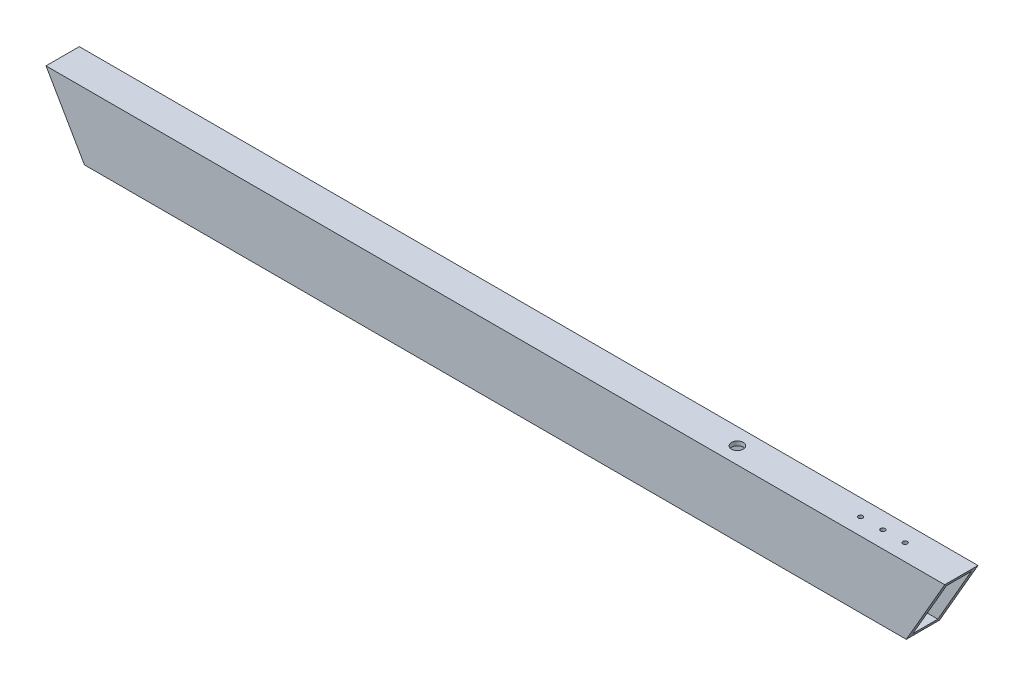
from build123d import *

# Parameters (mm, degrees)
SKETCH1_W                = 25.4
SKETCH1_H                = 50.8
SKETCH1_W_2              = 19.05
SKETCH1_H_2              = 44.45
BOSS_EXTRUDE1_DEPTH      = 342.9
CUT_EXTRUDE1_DEPTH       = 1
CUT_EXTRUDE1_DEPTH_BACK  = 26.4
CUT_EXTRUDE2_REACH       = 27.4
SKETCH3_R                = 11.1125
M3_CLEARANCE_HOLE1_D     = 3.4
M3_CLEARANCE_HOLE1_DEPTH = 3.175
SKETCH9_R                = 4.5
CUT_EXTRUDE3_DEPTH       = 12.7


with BuildPart() as part:
    # Sketch1 → Boss-Extrude1 (new body, symmetric)
    with BuildSketch(Plane(origin=(0, 0, 0), x_dir=(0, 0, -1), z_dir=(1, 0, 0))):
        Rectangle(SKETCH1_W, SKETCH1_H)
        Rectangle(SKETCH1_W_2, SKETCH1_H_2, mode=Mode.SUBTRACT)
    extrude(amount=BOSS_EXTRUDE1_DEPTH, both=True)

    # Sketch2 → Cut-Extrude1 (cut, two sides)
    with BuildSketch(Plane(origin=(0, 0, -12.7), x_dir=(-1, 0, 0), z_dir=(0, 0, -1))) as cut_extrude1_sk:
        Polygon((342.9, -25.4), (342.9, 25.4), (313.570606325, -25.4), align=None)
        Polygon((-342.9, -25.4), (-313.570606325, -25.4), (-342.9, 25.4), align=None)
    extrude(amount=CUT_EXTRUDE1_DEPTH, mode=Mode.SUBTRACT)
    extrude(cut_extrude1_sk.sketch, amount=-CUT_EXTRUDE1_DEPTH_BACK, mode=Mode.SUBTRACT)

    # Sketch3 → Cut-Extrude2 (cut, up to next)
    with BuildSketch(Plane(origin=(0, 0, -12.7), x_dir=(-1, 0, 0), z_dir=(0, 0, -1)), mode=Mode.PRIVATE) as cut_extrude2_sk1:
        with Locations((-234.95, 0)):
            Circle(SKETCH3_R)
    cut_extrude2_tool1 = extrude(cut_extrude2_sk1.sketch, amount=-CUT_EXTRUDE2_REACH, mode=Mode.PRIVATE) & part.part
    add(cut_extrude2_tool1.solids().sort_by_distance((234.95, 0, -12.7))[0], mode=Mode.SUBTRACT)
    # Sketch3 → Cut-Extrude2 (cut, up to next)
    with BuildSketch(Plane(origin=(0, 0, -12.7), x_dir=(-1, 0, 0), z_dir=(0, 0, -1)), mode=Mode.PRIVATE) as cut_extrude2_sk2:
        with Locations((-190.5, 0)):
            Circle(SKETCH3_R)
    cut_extrude2_tool2 = extrude(cut_extrude2_sk2.sketch, amount=-CUT_EXTRUDE2_REACH, mode=Mode.PRIVATE) & part.part
    add(cut_extrude2_tool2.solids().sort_by_distance((190.5, 0, -12.7))[0], mode=Mode.SUBTRACT)

    # M3 Clearance Hole1
    with Locations(Plane(origin=(0, 25.4, 0), x_dir=(1, 0, 0), z_dir=(0, 1, 0))):
        with Locations((299.991366478, 0), (282.991366478, 0), (265.991366478, 0)):
            Hole(M3_CLEARANCE_HOLE1_D / 2, depth=M3_CLEARANCE_HOLE1_DEPTH)

    # Sketch9 → Cut-Extrude3 (cut)
    with BuildSketch(Plane(origin=(0, 25.4, 0), x_dir=(1, 0, 0), z_dir=(0, 1, 0))):
        with Locations((171.991366478, 0)):
            Circle(SKETCH9_R)
    extrude(amount=-CUT_EXTRUDE3_DEPTH, mode=Mode.SUBTRACT)


solid = part.part
